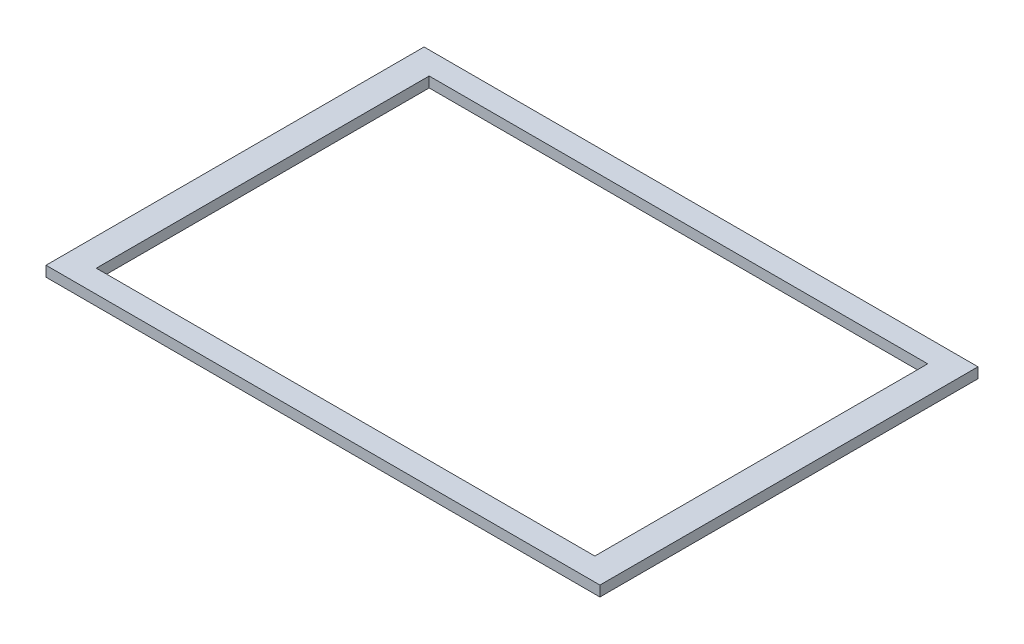
from build123d import *

# Parameters (mm, degrees)
SKETCH1_W           = 254
SKETCH1_H           = 173.355
SKETCH1_W_2         = 228.6
SKETCH1_H_2         = 152.654
BOSS_EXTRUDE1_DEPTH = 4.7625


with BuildPart() as part:
    # Sketch1 → Boss-Extrude1 (new body)
    with BuildSketch(Plane(origin=(0, 0, 0), x_dir=(1, 0, 0), z_dir=(0, 1, 0))):
        Rectangle(SKETCH1_W, SKETCH1_H)
        Rectangle(SKETCH1_W_2, SKETCH1_H_2, mode=Mode.SUBTRACT)
    extrude(amount=BOSS_EXTRUDE1_DEPTH)


solid = part.part
